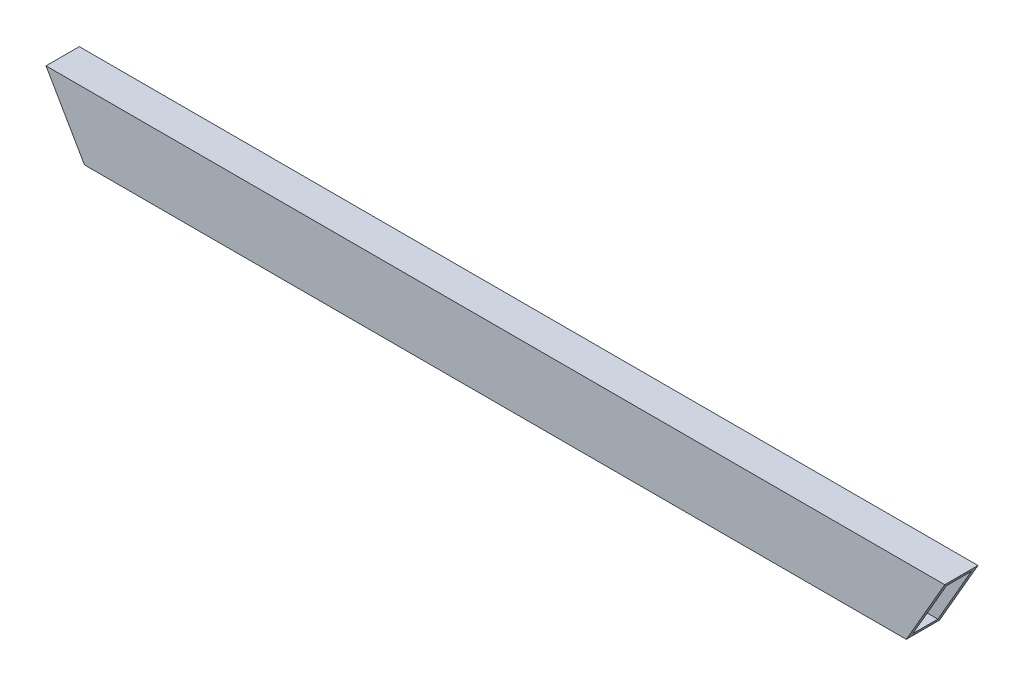
from build123d import *

# Parameters (mm, degrees)
SKETCH1_W               = 25.4
SKETCH1_H               = 50.8
SKETCH1_W_2             = 19.05
SKETCH1_H_2             = 44.45
BOSS_EXTRUDE1_DEPTH     = 342.9
CUT_EXTRUDE1_DEPTH      = 1
CUT_EXTRUDE1_DEPTH_BACK = 26.4


with BuildPart() as part:
    # Sketch1 → Boss-Extrude1 (new body, symmetric)
    with BuildSketch(Plane(origin=(0, 0, 0), x_dir=(0, 0, -1), z_dir=(1, 0, 0))):
        Rectangle(SKETCH1_W, SKETCH1_H)
        Rectangle(SKETCH1_W_2, SKETCH1_H_2, mode=Mode.SUBTRACT)
    extrude(amount=BOSS_EXTRUDE1_DEPTH, both=True)

    # Sketch2 → Cut-Extrude1 (cut, two sides)
    with BuildSketch(Plane(origin=(0, 0, -12.7), x_dir=(-1, 0, 0), z_dir=(0, 0, -1))) as cut_extrude1_sk:
        Polygon((342.9, -25.4), (342.9, 25.4), (313.570606325, -25.4), align=None)
        Polygon((-342.9, -25.4), (-313.570606325, -25.4), (-342.9, 25.4), align=None)
    extrude(amount=CUT_EXTRUDE1_DEPTH, mode=Mode.SUBTRACT)
    extrude(cut_extrude1_sk.sketch, amount=-CUT_EXTRUDE1_DEPTH_BACK, mode=Mode.SUBTRACT)


solid = part.part
